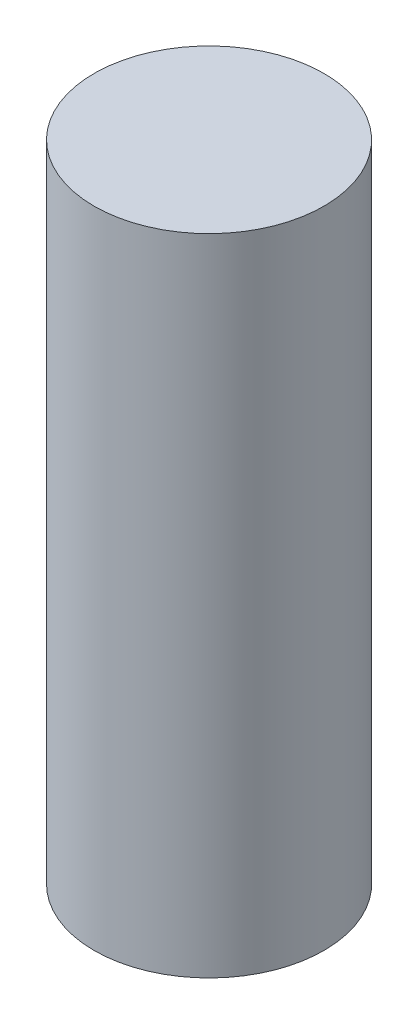
from build123d import *

# Parameters (mm, degrees)
SKETCH1_R           = 2.675
BOSS_EXTRUDE1_DEPTH = 15


with BuildPart() as part:
    # Sketch1 → Boss-Extrude1 (new body)
    with BuildSketch(Plane(origin=(0, 0, 0), x_dir=(1, 0, 0), z_dir=(0, 1, 0))):
        Circle(SKETCH1_R)
    extrude(amount=BOSS_EXTRUDE1_DEPTH)


solid = part.part
